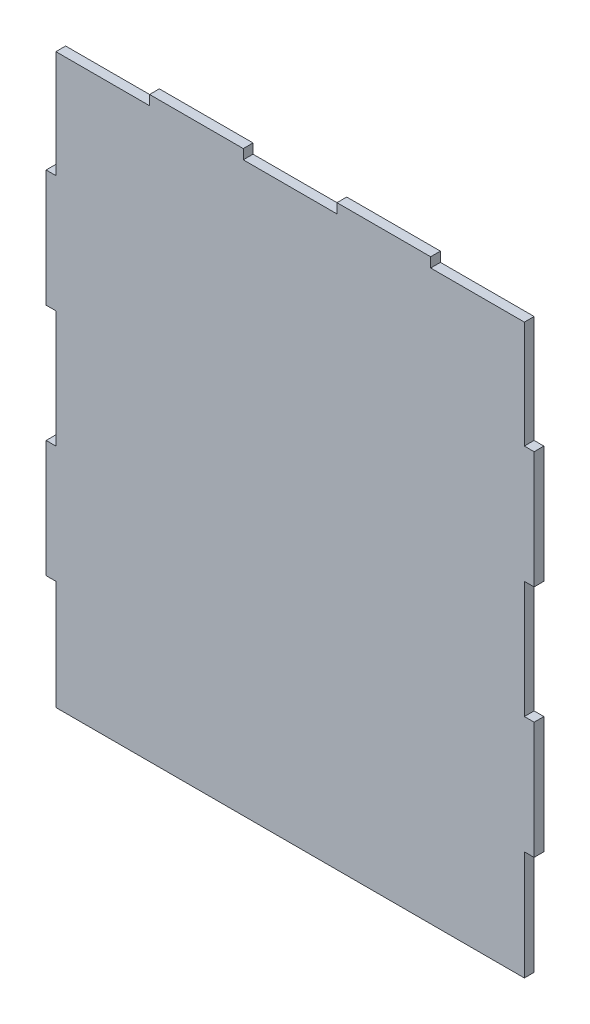
from build123d import *

# Parameters (mm, degrees)
BOSS_EXTRU_1_DEPTH = 5


with BuildPart() as part:
    # Esquisse1 → Boss.-Extru.1 (new body)
    with BuildSketch(Plane.XY):
        Polygon((5, 291), (5, 236), (0, 236), (0, 176), (5, 176), (5, 116), (0, 116), (0, 56), (5, 56), (5, 0), (245, 0), (245, 56), (250, 56), (250, 116), (245, 116), (245, 176), (250, 176), (250, 236), (245, 236), (245, 291), (197, 291), (197, 296), (149, 296), (149, 291), (101, 291), (101, 296), (53, 296), (53, 291), align=None)
    extrude(amount=BOSS_EXTRU_1_DEPTH)


solid = part.part
